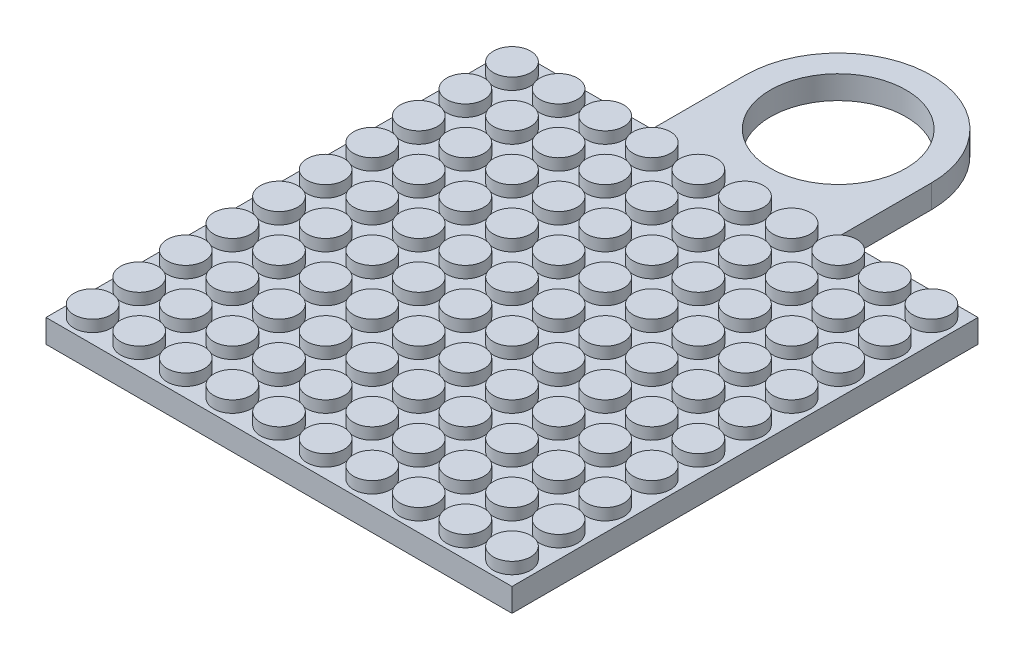
from build123d import *

# Parameters (mm, degrees)
SKETCH1_W               = 10
SKETCH1_H               = 10
PLATE_DEPTH             = 0.5
SKETCH2_R               = 0.4
ROD_DEPTH               = 0.25
LPATTERN1_COUNT         = 10
LPATTERN1_PITCH         = 1
LPATTERN1_COUNT_DIR2    = 10
LPATTERN1_PITCH_DIR2    = 1
BOSS_EXTRUDE3_DEPTH     = 0.5
SKETCH5_R               = 1.455938962
CUT_EXTRUDE1_DEPTH      = 0.5
CUT_EXTRUDE1_DEPTH_BACK = 1.5


with BuildPart() as part:
    # Sketch1 → Plate (new body)
    with BuildSketch(Plane(origin=(0, 0, 0), x_dir=(1, 0, 0), z_dir=(0, 1, 0))):
        Rectangle(SKETCH1_W, SKETCH1_H)
    extrude(amount=PLATE_DEPTH)

    # Sketch2 → Rod (add)
    with BuildSketch(Plane(origin=(0, 0.5, 0), x_dir=(1, 0, 0), z_dir=(0, 1, 0))):
        with Locations((-4.5, -4.5)):
            Circle(SKETCH2_R)
    rod = extrude(amount=ROD_DEPTH)

    # LPattern1: Rod 10 × 10
    with Locations(*[(i * LPATTERN1_PITCH, 0, -j * LPATTERN1_PITCH_DIR2) for i in range(LPATTERN1_COUNT) for j in range(LPATTERN1_COUNT_DIR2) if (i, j) != (0, 0)]):
        add(rod)

    # Sketch4 → Boss-Extrude3 (add)
    with BuildSketch(Plane(origin=(0, 0, 0), x_dir=(1, 0, 0), z_dir=(0, 1, 0))):
        with BuildLine():
            Line((-2, 7), (-2, 5))
            Line((-2, 5), (2, 5))
            Line((2, 5), (2, 7))
            ThreePointArc((2, 7), (0, 9), (-2, 7))
        make_face()
    extrude(amount=BOSS_EXTRUDE3_DEPTH)

    # Sketch5 → Cut-Extrude1 (cut, two sides)
    with BuildSketch(Plane(origin=(0, 0.5, 0), x_dir=(1, 0, 0), z_dir=(0, 1, 0))) as cut_extrude1_sk:
        with Locations((0, 7)):
            Circle(SKETCH5_R)
    extrude(amount=CUT_EXTRUDE1_DEPTH, mode=Mode.SUBTRACT)
    extrude(cut_extrude1_sk.sketch, amount=-CUT_EXTRUDE1_DEPTH_BACK, mode=Mode.SUBTRACT)


solid = part.part
